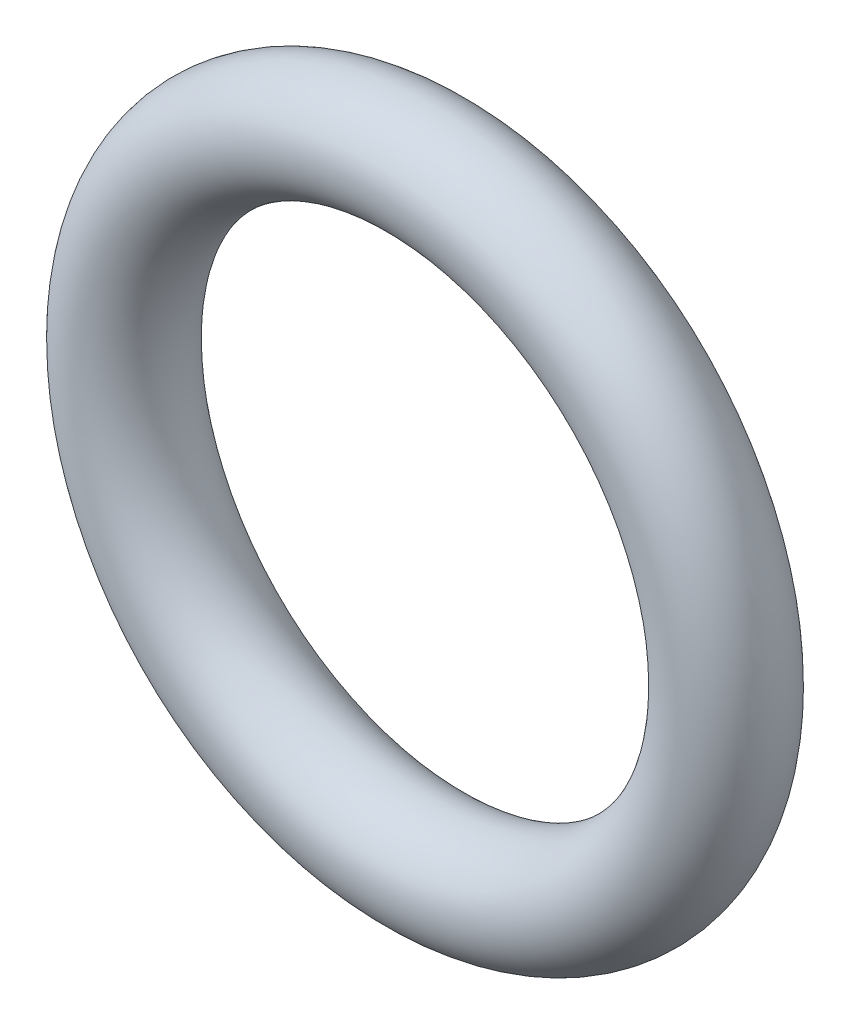
from build123d import *

# Parameters (mm, degrees)
SKETCH2_R = 0.5


with BuildPart() as part:
    # Sketch2 → Revolve1 (revolve)
    with BuildSketch(Plane(origin=(0, 0, 0), x_dir=(1, 0, 0), z_dir=(0, 1, 0))):
        with Locations((2.75, 0)):
            Circle(SKETCH2_R)
    revolve(axis=Axis((0, 0, -0.5), (0, 0, 1)))


solid = part.part
